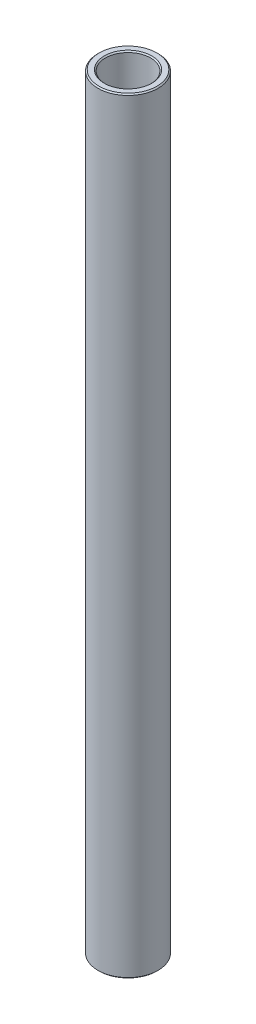
from build123d import *

# Parameters (mm, degrees)
SKETCH1_W     = 1.5875
SKETCH1_H     = 161.737331671
CHAMFER1_SIZE = 0.254


with BuildPart() as part:
    # Sketch1 → Revolve1 (revolve)
    with BuildSketch(Plane.XY):
        with Locations((5.55625, 151.512360801)):
            Rectangle(SKETCH1_W, SKETCH1_H)
    revolve(axis=Axis((0, 61.118694965, 0), (0, 1, 0)))

    # Chamfer1
    chamfer1_edges = [part.edges().sort_by_distance(p)[0] for p in [
        (-6.35, 70.643694965, 0),
        (-6.35, 232.381026636, 0),
        (-4.7625, 232.381026636, 0),
        (-4.7625, 70.643694965, 0),
    ]]
    chamfer(chamfer1_edges, length=CHAMFER1_SIZE)


solid = part.part
